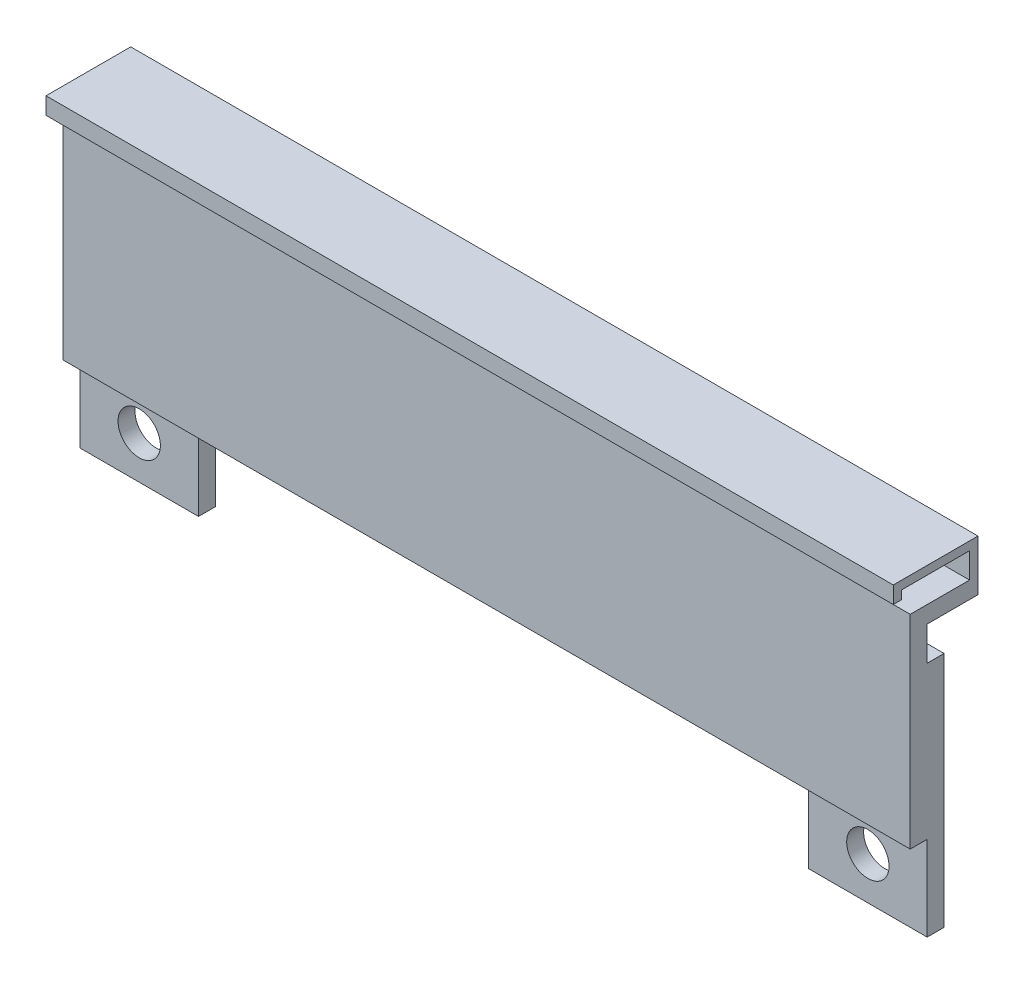
from build123d import *

# Parameters (mm, degrees)
ESQUISSE1_W             = 100
ESQUISSE1_H             = 12
ESQUISSE1_R             = 2.5
BOSS_EXTRU_1_DEPTH      = 2
ESQUISSE2_W             = 100
ESQUISSE2_H             = 2
BOSS_EXTRU_2_DEPTH      = 2
ESQUISSE3_W             = 100
ESQUISSE3_H             = 4
BOSS_EXTRU_3_DEPTH      = 22
ESQUISSE4_W             = 100
ESQUISSE4_H             = 2
ENL_V_MAT_EXTRU_1_DEPTH = 6
ESQUISSE5_W             = 100
ESQUISSE5_H             = 2
BOSS_EXTRU_4_DEPTH      = 6
ESQUISSE6_W             = 100
ESQUISSE6_H             = 6
BOSS_EXTRU_5_DEPTH      = 1
ESQUISSE9_W             = 100
ESQUISSE9_H             = 1
BOSS_EXTRU_8_DEPTH      = 9
ESQUISSE10_W            = 100
ESQUISSE10_H            = 1
BOSS_EXTRU_9_DEPTH      = 1
ESQUISSE11_W            = 100
ESQUISSE11_H            = 28
ESQUISSE11_R            = 2.5
BOSS_EXTRU_10_DEPTH     = 2
ESQUISSE12_W            = 100
ESQUISSE12_H            = 28
ENL_V_MAT_EXTRU_2_DEPTH = 2
ESQUISSE13_W            = 72
ESQUISSE13_H            = 10
ENL_V_MAT_EXTRU_3_DEPTH = 2


with BuildPart() as part:
    # Esquisse1 → Boss.-Extru.1 (new body)
    with BuildSketch(Plane.XY):
        with Locations((-50, 6)):
            Rectangle(ESQUISSE1_W, ESQUISSE1_H)
        with Locations((-93, 5)):
            Circle(ESQUISSE1_R, mode=Mode.SUBTRACT)
        with Locations((-7, 5)):
            Circle(ESQUISSE1_R, mode=Mode.SUBTRACT)
    extrude(amount=BOSS_EXTRU_1_DEPTH)

    # Esquisse2 → Boss.-Extru.2 (add)
    with BuildSketch(Plane(origin=(0, 0, 0), x_dir=(-1, 0, 0), z_dir=(0, 0, -1))):
        with Locations((50, 11)):
            Rectangle(ESQUISSE2_W, ESQUISSE2_H)
    extrude(amount=BOSS_EXTRU_2_DEPTH)

    # Esquisse3 → Boss.-Extru.3 (add)
    with BuildSketch(Plane(origin=(0, 12, 0), x_dir=(1, 0, 0), z_dir=(0, 1, 0))):
        with Locations((-50, 0)):
            Rectangle(ESQUISSE3_W, ESQUISSE3_H)
    extrude(amount=BOSS_EXTRU_3_DEPTH)

    # Esquisse4 → Enlèv. mat.-Extru.1 (cut)
    with BuildSketch(Plane(origin=(0, 34, 0), x_dir=(1, 0, 0), z_dir=(0, 1, 0))):
        with Locations((-50, -1)):
            Rectangle(ESQUISSE4_W, ESQUISSE4_H)
    extrude(amount=-ENL_V_MAT_EXTRU_1_DEPTH, mode=Mode.SUBTRACT)

    # Esquisse5 → Boss.-Extru.4 (add)
    with BuildSketch(Plane(origin=(0, 0, -2), x_dir=(-1, 0, 0), z_dir=(0, 0, -1))):
        with Locations((50, 33)):
            Rectangle(ESQUISSE5_W, ESQUISSE5_H)
    extrude(amount=BOSS_EXTRU_4_DEPTH)

    # Esquisse6 → Boss.-Extru.5 (add)
    with BuildSketch(Plane(origin=(0, 0, -8), x_dir=(-1, 0, 0), z_dir=(0, 0, -1))):
        with Locations((50, 35)):
            Rectangle(ESQUISSE6_W, ESQUISSE6_H)
    extrude(amount=-BOSS_EXTRU_5_DEPTH)

    # Esquisse9 → Boss.-Extru.8 (add)
    with BuildSketch(Plane.XY.offset(-7)):
        with Locations((-50, 37.5)):
            Rectangle(ESQUISSE9_W, ESQUISSE9_H)
    extrude(amount=BOSS_EXTRU_8_DEPTH)

    # Esquisse10 → Boss.-Extru.9 (add)
    with BuildSketch(Plane.XZ.offset(-37)):
        with Locations((-50, 1.5)):
            Rectangle(ESQUISSE10_W, ESQUISSE10_H)
    extrude(amount=BOSS_EXTRU_9_DEPTH)

    # Esquisse11 → Boss.-Extru.10 (add)
    with BuildSketch(Plane(origin=(0, 0, -2), x_dir=(-1, 0, 0), z_dir=(0, 0, -1))):
        with Locations((50, 14)):
            Rectangle(ESQUISSE11_W, ESQUISSE11_H)
        with Locations((93, 5)):
            Circle(ESQUISSE11_R, mode=Mode.SUBTRACT)
        with Locations((7, 5)):
            Circle(ESQUISSE11_R, mode=Mode.SUBTRACT)
    extrude(amount=BOSS_EXTRU_10_DEPTH)

    # Esquisse12 → Enlèv. mat.-Extru.2 (cut)
    with BuildSketch(Plane.XY.offset(2)):
        with Locations((-50, 14)):
            Rectangle(ESQUISSE12_W, ESQUISSE12_H)
    extrude(amount=-ENL_V_MAT_EXTRU_2_DEPTH, mode=Mode.SUBTRACT)

    # Esquisse13 → Enlèv. mat.-Extru.3 (cut)
    with BuildSketch(Plane.XY.offset(-2)):
        with Locations((-50, 5)):
            Rectangle(ESQUISSE13_W, ESQUISSE13_H)
    extrude(amount=-ENL_V_MAT_EXTRU_3_DEPTH, mode=Mode.SUBTRACT)


solid = part.part
